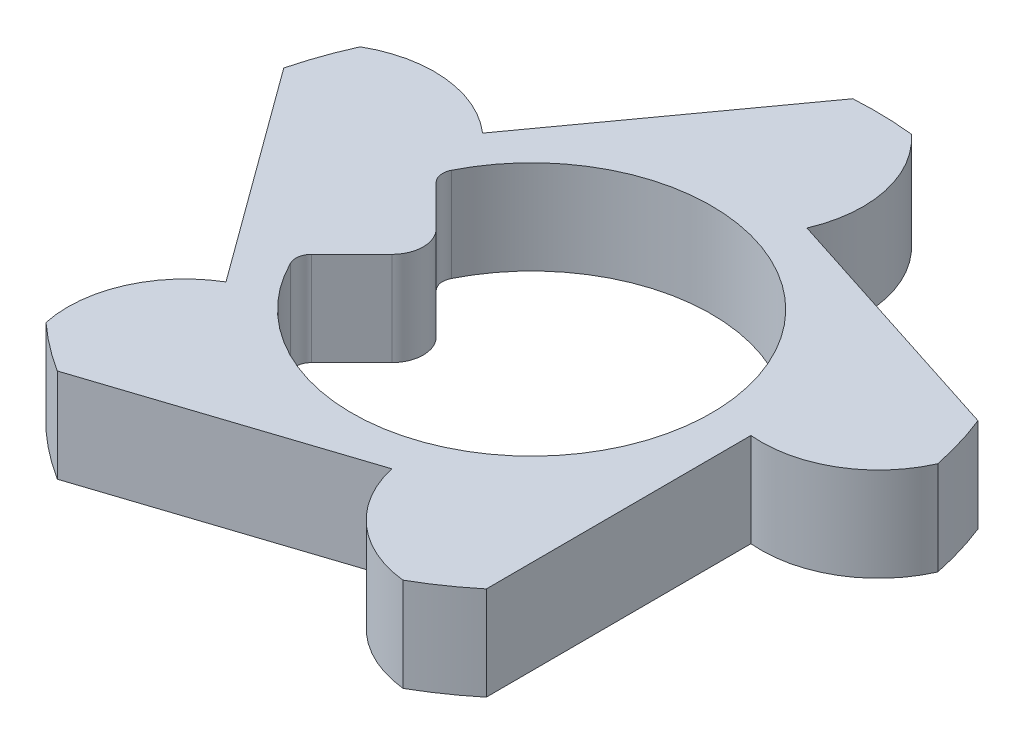
from build123d import *

# Parameters (mm, degrees)
BOSS_EXTRUDE1_DEPTH = 0.6
CUT_EXTRUDE1_REACH  = 2.6
FILLET1_R           = 0.1
FILLET2_R           = 0.2


with BuildPart() as part:
    # Sketch1 → Boss-Extrude1 (new body)
    with BuildSketch(Plane(origin=(0, 0, 0), x_dir=(1, 0, 0), z_dir=(0, 1, 0))):
        with BuildLine():
            Line((-1.130713076, -0.825522828), (-2.131397859, 0.545108401))
            ThreePointArc((-2.131397859, 0.545108401), (-2.07578756, 0.7287702), (-2.004384052, 0.906887298))
            ThreePointArc((-2.004384052, 0.906887298), (-1.555532522, 1.003410855), (-1.134528421, 0.820271456))
            Line((-1.134528421, 0.820271456), (-0.140209263, 2.195527582))
            ThreePointArc((-0.140209263, 2.195527582), (0.051648015, 2.199393662), (0.243112339, 2.186526101))
            ThreePointArc((0.243112339, 2.186526101), (0.473614448, 1.789470348), (0.42953595, 1.332478468))
            Line((0.42953595, 1.332478468), (2.044743768, 0.811802268))
            ThreePointArc((2.044743768, 0.811802268), (2.107707789, 0.630529838), (2.154635741, 0.444460149))
            ThreePointArc((2.154635741, 0.444460149), (1.848242349, 0.102542642), (1.399996238, 0.003245527))
            Line((1.399996238, 0.003245527), (1.40393041, -1.693806188))
            ThreePointArc((1.40393041, -1.693806188), (1.250987037, -1.809704792), (1.088525782, -1.911834622))
            ThreePointArc((1.088525782, -1.911834622), (0.668662143, -1.726095511), (0.435709309, -1.330472622))
            Line((0.435709309, -1.330472622), (-1.177067057, -1.858632063))
            ThreePointArc((-1.177067057, -1.858632063), (-1.33455528, -1.748988909), (-1.48188981, -1.626038927))
            ThreePointArc((-1.48188981, -1.626038927), (-1.434986417, -1.169328335), (-1.130713076, -0.825522828))
        make_face()
    extrude(amount=BOSS_EXTRUDE1_DEPTH)

    # Sketch2 → Cut-Extrude1 (cut, up to next)
    with BuildSketch(Plane(origin=(0, 0.6, 0), x_dir=(1, 0, 0), z_dir=(0, 1, 0)), mode=Mode.PRIVATE) as cut_extrude1_sk1:
        with BuildLine():
            Line((-1.059104505, 0.448104505), (-0.611, 0))
            Line((-0.611, 0), (-1.059104505, -0.448104505))
            ThreePointArc((-1.059104505, -0.448104505), (1.15, 0), (-1.059104505, 0.448104505))
        make_face()
    cut_extrude1_tool1 = extrude(cut_extrude1_sk1.sketch, amount=-CUT_EXTRUDE1_REACH, mode=Mode.PRIVATE) & part.part
    add(cut_extrude1_tool1.solids().sort_by_distance((0.062233, 0.6, 0))[0], mode=Mode.SUBTRACT)

    # Fillet1
    fillet1_edges = [part.edges().sort_by_distance(p)[0] for p in [
        (-1.059104505, 0.3, -0.448104505),
        (-1.059104505, 0.3, 0.448104505),
    ]]
    fillet(fillet1_edges, radius=FILLET1_R)

    # Fillet2
    fillet2_edges = [part.edges().sort_by_distance(p)[0] for p in [
        (-0.611, 0.3, 0),
    ]]
    fillet(fillet2_edges, radius=FILLET2_R)


solid = part.part
